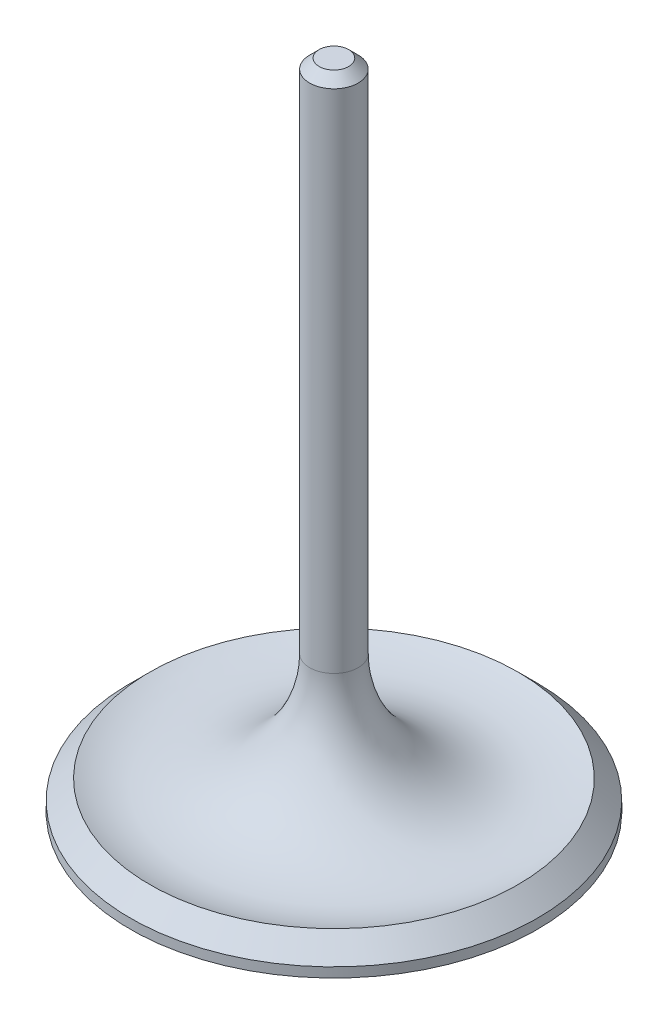
from build123d import *

# Parameters (mm, degrees)
CHAFL_N1_SIZE = 1.25


with BuildPart() as part:
    # Croquis1 → Revolución1 (revolve)
    with BuildSketch(Plane(origin=(0, 0, 0), x_dir=(0, 0, -1), z_dir=(1, 0, 0))):
        with BuildLine():
            Line((0, 0), (0, 85.55))
            Line((0, 85.55), (3.18, 85.55))
            Line((3.18, 85.55), (3.18, 17.954698654))
            ThreePointArc((3.18, 17.954698654), (9.896609701, 5.315721242), (24.13, 3.81))
            Line((24.13, 3.81), (26.67, 1.27))
            Line((26.67, 1.27), (26.67, 0))
            Line((26.67, 0), (0, 0))
        make_face()
    revolve(axis=Axis((0, 0, 0), (0, 1, 0)))

    # Chaflán1
    chafl_n1_edges = [part.edges().sort_by_distance(p)[0] for p in [
        (0, 85.55, 3.18),
    ]]
    chamfer(chafl_n1_edges, length=CHAFL_N1_SIZE)


solid = part.part
